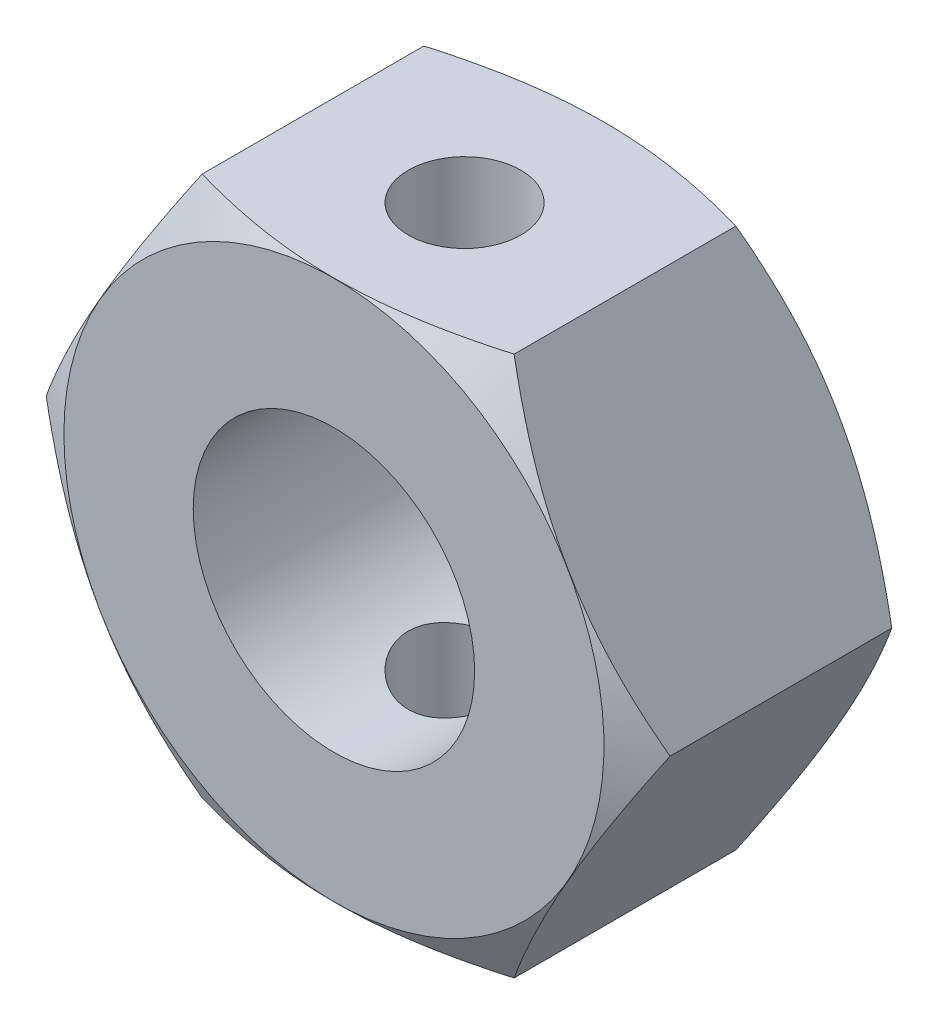
from build123d import *

# Parameters (mm, degrees)
BASE_EXTRUSION_DEPTH    = 9.6
ESQUISSE2_R             = 5
ENL_V_MAT_EXTRU_1_DEPTH = 10.6
ESQUISSE4_R             = 2
ENL_V_MAT_EXTRU_2_DEPTH = 20.2


with BuildPart() as part:
    # Esquisse1 → Base-Extrusion (new body)
    with BuildSketch(Plane.XY):
        Polygon((-11.085125168, 0), (-5.542562584, 9.6), (5.542562584, 9.6), (11.085125168, 0), (5.542562584, -9.6), (-5.542562584, -9.6), align=None)
    extrude(amount=BASE_EXTRUSION_DEPTH)

    # Esquisse2 → Enl_v. mat.-Extru.1 (cut, through all)
    with BuildSketch(Plane.XY.offset(9.6)):
        Circle(ESQUISSE2_R)
    extrude(amount=-ENL_V_MAT_EXTRU_1_DEPTH, mode=Mode.SUBTRACT)

    # Esquisse4 → Enl_v. mat.-Extru.2 (cut, through all)
    with BuildSketch(Plane(origin=(0, 9.6, 0), x_dir=(-1, 0, 0), z_dir=(0, 1, 0))):
        with Locations((0, 4.956948818)):
            Circle(ESQUISSE4_R)
    extrude(amount=-ENL_V_MAT_EXTRU_2_DEPTH, mode=Mode.SUBTRACT)

    # Esquisse6 → Enl_vement de mati_re-R_volution2 (revolve, cut)
    with BuildSketch(Plane(origin=(0, 0, 0), x_dir=(1, 0, 0), z_dir=(0, 1, 0))):
        Polygon((-11.085125168, 0), (-9.595561474, 0), (-11.085125168, -0.86), align=None)
        Polygon((-11.085125168, -8.74), (-11.085125168, -9.6), (-9.595561474, -9.6), align=None)
    revolve(axis=Axis((0, 0, 0), (0, 0, 1)), mode=Mode.SUBTRACT)


solid = part.part
